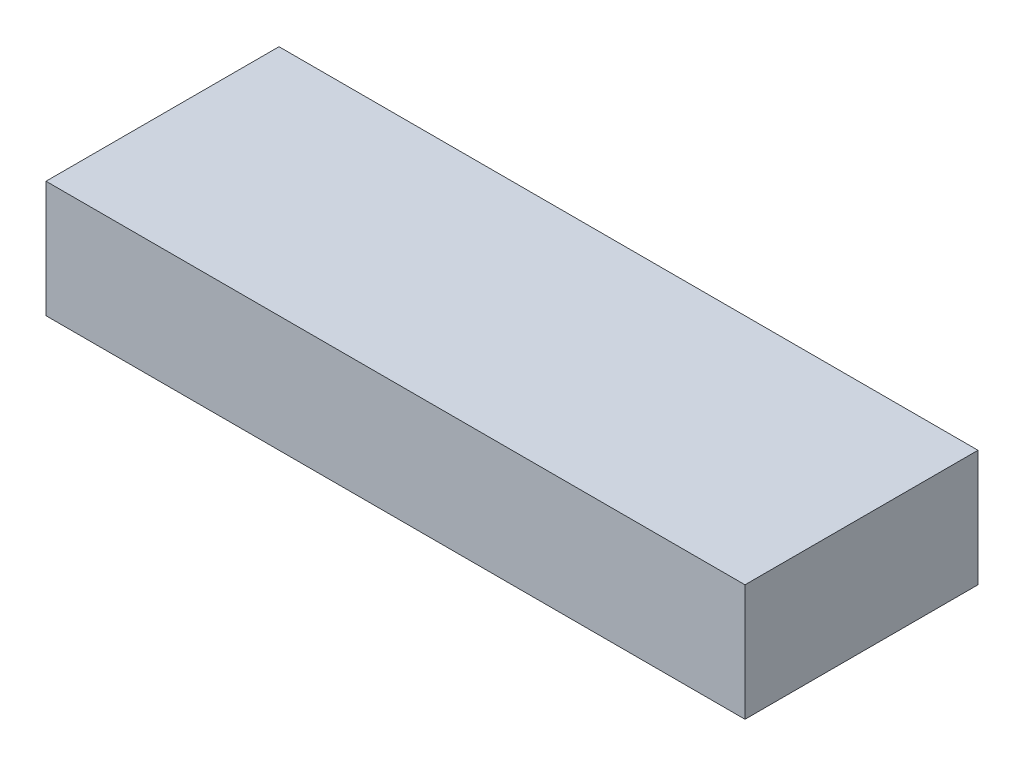
from build123d import *

# Parameters (mm, degrees)
SKETCH1_W           = 152.4
SKETCH1_H           = 50.8
BOSS_EXTRUDE1_DEPTH = 25.4


with BuildPart() as part:
    # Sketch1 → Boss-Extrude1 (new body)
    with BuildSketch(Plane(origin=(0, 0, 0), x_dir=(1, 0, 0), z_dir=(0, 1, 0))):
        Rectangle(SKETCH1_W, SKETCH1_H)
    extrude(amount=BOSS_EXTRUDE1_DEPTH)


solid = part.part
